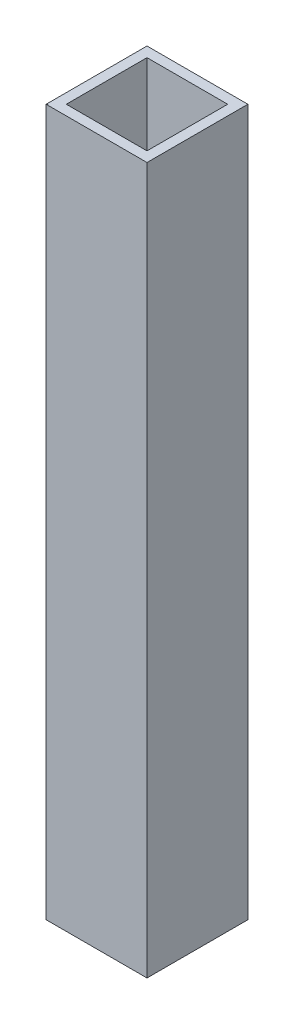
from build123d import *

# Parameters (mm, degrees)
SKETCH_1_W      = 10
SKETCH_1_H      = 10
SKETCH_1_W_2    = 8
SKETCH_1_H_2    = 8
EXTRUDE_1_DEPTH = 70


with BuildPart() as part:
    # 草图1 → 凸台-拉伸1 (new body)
    with BuildSketch(Plane.XZ.offset(70)):
        Rectangle(SKETCH_1_W, SKETCH_1_H)
        Rectangle(SKETCH_1_W_2, SKETCH_1_H_2, mode=Mode.SUBTRACT)
    extrude(amount=-EXTRUDE_1_DEPTH)


solid = part.part
